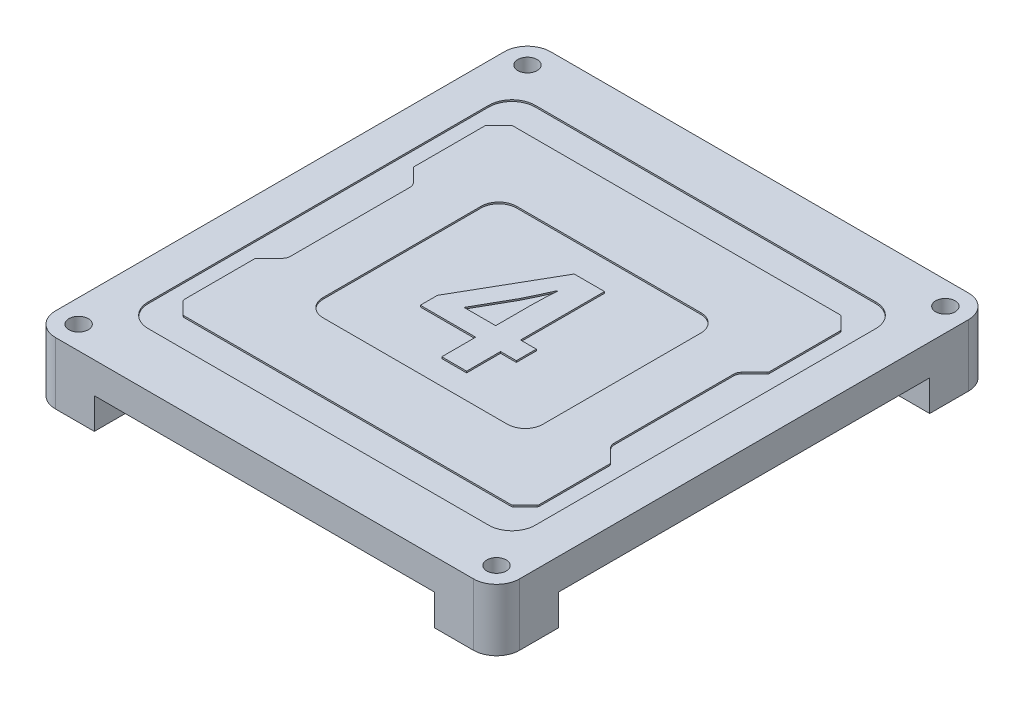
from build123d import *

# Parameters (mm, degrees)
EXTRUDE_1_DEPTH     = 4
EXTRUDE_2_DEPTH     = 4
SKETCH_3_R          = 1.25
CUT_EXTRUDE_1_DEPTH = 15
CUT_EXTRUDE_2_DEPTH = 0.2
EXTRUDE_5_DEPTH     = 0.2
EXTRUDE_6_DEPTH     = 0.2
SKETCH_13_R         = 2.280555424
SKETCH_13_R_2       = 2.93479419
SKETCH_13_R_3       = 2.630805897
SKETCH_13_R_4       = 2.84821008
EXTRUDE_7_DEPTH     = 0.2


with BuildPart() as part:
    # 草图1 → 凸台-拉伸1 (new body)
    with BuildSketch(Plane(origin=(0, 0, 0), x_dir=(1, 0, 0), z_dir=(0, 1, 0))):
        with BuildLine():
            Line((-27.00005461, -31.987363475), (27.00005461, -31.987363475))
            ThreePointArc((27.00005461, -31.987363475), (29.112398272, -31.112402082), (29.987359665, -29.00005842))
            Line((29.987359665, -29.00005842), (29.987359665, 29.00005842))
            ThreePointArc((29.987359665, 29.00005842), (29.112398272, 31.112402082), (27.00005461, 31.987363475))
            Line((27.00005461, 31.987363475), (-27.00005461, 31.987363475))
            ThreePointArc((-27.00005461, 31.987363475), (-29.112398272, 31.112402082), (-29.987359665, 29.00005842))
            Line((-29.987359665, 29.00005842), (-29.987359665, -29.00005842))
            ThreePointArc((-29.987359665, -29.00005842), (-29.112398272, -31.112402082), (-27.00005461, -31.987363475))
        make_face()
    extrude(amount=EXTRUDE_1_DEPTH)

    # 草图2 → 凸台-拉伸2 (add)
    with BuildSketch(Plane.XZ):
        with BuildLine():
            Line((-21.987359665, 23.987363475), (-21.987359665, 31.987363475))
            Line((-21.987359665, 31.987363475), (-27.00005461, 31.987363475))
            ThreePointArc((-27.00005461, 31.987363475), (-29.112398272, 31.112402082), (-29.987359665, 29.00005842))
            Line((-29.987359665, 29.00005842), (-29.987359665, 23.987363475))
            Line((-29.987359665, 23.987363475), (-21.987359665, 23.987363475))
        make_face()
        with BuildLine():
            Line((21.987359665, -23.987363475), (21.987359665, -31.987363475))
            Line((21.987359665, -31.987363475), (27.00005461, -31.987363475))
            ThreePointArc((27.00005461, -31.987363475), (29.112398272, -31.112402082), (29.987359665, -29.00005842))
            Line((29.987359665, -29.00005842), (29.987359665, -23.987363475))
            Line((29.987359665, -23.987363475), (21.987359665, -23.987363475))
        make_face()
        with BuildLine():
            Line((21.987359665, 23.987363475), (29.987359665, 23.987363475))
            Line((29.987359665, 23.987363475), (29.987359665, 29.00005842))
            ThreePointArc((29.987359665, 29.00005842), (29.112398272, 31.112402082), (27.00005461, 31.987363475))
            Line((27.00005461, 31.987363475), (21.987359665, 31.987363475))
            Line((21.987359665, 31.987363475), (21.987359665, 23.987363475))
        make_face()
        with BuildLine():
            Line((-29.987359665, -23.987363475), (-29.987359665, -29.00005842))
            ThreePointArc((-29.987359665, -29.00005842), (-29.112398272, -31.112402082), (-27.00005461, -31.987363475))
            Line((-27.00005461, -31.987363475), (-21.987359665, -31.987363475))
            Line((-21.987359665, -31.987363475), (-21.987359665, -23.987363475))
            Line((-21.987359665, -23.987363475), (-29.987359665, -23.987363475))
        make_face()
    extrude(amount=EXTRUDE_2_DEPTH)

    # 草图3 → 切除-拉伸1 (cut)
    with BuildSketch(Plane.XZ.offset(4)):
        with Locations(Location((-27.00005461, 29.00005842, 0), (0, 0, 270))):
            Circle(SKETCH_3_R)
        with Locations(Location((27.00005461, 29.00005842, 0), (0, 0, 270))):
            Circle(SKETCH_3_R)
        with Locations(Location((27.00005461, -29.00005842, 0), (0, 0, 270))):
            Circle(SKETCH_3_R)
        with Locations(Location((-27.00005461, -29.00005842, 0), (0, 0, 270))):
            Circle(SKETCH_3_R)
    extrude(amount=-CUT_EXTRUDE_1_DEPTH, mode=Mode.SUBTRACT)

    # 草图4 → 切除-拉伸2 (cut)
    with BuildSketch(Plane(origin=(0, 4, 0), x_dir=(1, 0, 0), z_dir=(0, 1, 0))):
        with BuildLine():
            Line((-22, -25), (22, -25))
            ThreePointArc((22, -25), (24.121320344, -24.121320344), (25, -22))
            Line((25, -22), (25, 22))
            ThreePointArc((25, 22), (24.121320344, 24.121320344), (22, 25))
            Line((22, 25), (-22, 25))
            ThreePointArc((-22, 25), (-24.121320344, 24.121320344), (-25, 22))
            Line((-25, 22), (-25, -22))
            ThreePointArc((-25, -22), (-24.121320344, -24.121320344), (-22, -25))
        make_face()
    extrude(amount=-CUT_EXTRUDE_2_DEPTH, mode=Mode.SUBTRACT)

    # 草图9 → 凸台-拉伸5 (add)
    with BuildSketch(Plane(origin=(0, 3.8, 0), x_dir=(1, 0, 0), z_dir=(0, 1, 0))):
        with BuildLine():
            ThreePointArc((-21.208751083, 8.458751083), (-20.987642877, 8.127839267), (-20.91, 7.737502166))
            Line((-20.91, 7.737502166), (-20.91, -7.737502166))
            ThreePointArc((-20.91, -7.737502166), (-20.987642877, -8.127839267), (-21.208751083, -8.458751083))
            Line((-21.208751083, -8.458751083), (-22.850416306, -10.100416306))
            ThreePointArc((-22.850416306, -10.100416306), (-22.924119041, -10.210720244), (-22.95, -10.340832611))
            Line((-22.95, -10.340832611), (-22.95, -19.409167389))
            ThreePointArc((-22.95, -19.409167389), (-22.924119041, -19.539279756), (-22.850416306, -19.649583694))
            Line((-22.850416306, -19.649583694), (-21.349583694, -21.150416306))
            ThreePointArc((-21.349583694, -21.150416306), (-21.239279756, -21.224119041), (-21.109167389, -21.25))
            Line((-21.109167389, -21.25), (21.109167389, -21.25))
            ThreePointArc((21.109167389, -21.25), (21.239279756, -21.224119041), (21.349583694, -21.150416306))
            Line((21.349583694, -21.150416306), (22.850416306, -19.649583694))
            ThreePointArc((22.850416306, -19.649583694), (22.924119041, -19.539279756), (22.95, -19.409167389))
            Line((22.95, -19.409167389), (22.95, -10.340832611))
            ThreePointArc((22.95, -10.340832611), (22.924119041, -10.210720244), (22.850416306, -10.100416306))
            Line((22.850416306, -10.100416306), (21.208751083, -8.458751083))
            ThreePointArc((21.208751083, -8.458751083), (20.987642877, -8.127839267), (20.91, -7.737502166))
            Line((20.91, -7.737502166), (20.91, 7.737502166))
            ThreePointArc((20.91, 7.737502166), (20.987642877, 8.127839267), (21.208751083, 8.458751083))
            Line((21.208751083, 8.458751083), (22.850416306, 10.100416306))
            ThreePointArc((22.850416306, 10.100416306), (22.924119041, 10.210720244), (22.95, 10.340832611))
            Line((22.95, 10.340832611), (22.95, 19.409167389))
            ThreePointArc((22.95, 19.409167389), (22.924119041, 19.539279756), (22.850416306, 19.649583694))
            Line((22.850416306, 19.649583694), (21.349583694, 21.150416306))
            ThreePointArc((21.349583694, 21.150416306), (21.239279756, 21.224119041), (21.109167389, 21.25))
            Line((21.109167389, 21.25), (-21.109167389, 21.25))
            ThreePointArc((-21.109167389, 21.25), (-21.239279756, 21.224119041), (-21.349583694, 21.150416306))
            Line((-21.349583694, 21.150416306), (-22.850416306, 19.649583694))
            ThreePointArc((-22.850416306, 19.649583694), (-22.924119041, 19.539279756), (-22.95, 19.409167389))
            Line((-22.95, 19.409167389), (-22.95, 10.340832611))
            ThreePointArc((-22.95, 10.340832611), (-22.924119041, 10.210720244), (-22.850416306, 10.100416306))
            Line((-22.850416306, 10.100416306), (-21.208751083, 8.458751083))
        make_face()
        with BuildLine():
            ThreePointArc((-14.688, -17.765), (-16.15, -19.227), (-17.612, -17.765))
            ThreePointArc((-17.612, -17.765), (-16.15, -16.303), (-14.688, -17.765))
        make_face(mode=Mode.SUBTRACT)
        with BuildLine():
            ThreePointArc((14.688, -17.765), (16.15, -16.303), (17.612, -17.765))
            ThreePointArc((17.612, -17.765), (16.15, -19.227), (14.688, -17.765))
        make_face(mode=Mode.SUBTRACT)
        with BuildLine():
            Line((11.9, -12.495), (-11.9, -12.495))
            ThreePointArc((-11.9, -12.495), (-13.522810063, -11.822810063), (-14.195, -10.2))
            Line((-14.195, -10.2), (-14.195, 10.2))
            ThreePointArc((-14.195, 10.2), (-13.522810063, 11.822810063), (-11.9, 12.495))
            Line((-11.9, 12.495), (11.9, 12.495))
            ThreePointArc((11.9, 12.495), (13.522810063, 11.822810063), (14.195, 10.2))
            Line((14.195, 10.2), (14.195, -10.2))
            ThreePointArc((14.195, -10.2), (13.522810063, -11.822810063), (11.9, -12.495))
        make_face(mode=Mode.SUBTRACT)
        with BuildLine():
            ThreePointArc((-14.688, 17.765), (-16.15, 16.303), (-17.612, 17.765))
            ThreePointArc((-17.612, 17.765), (-16.15, 19.227), (-14.688, 17.765))
        make_face(mode=Mode.SUBTRACT)
        with BuildLine():
            ThreePointArc((17.612, 17.765), (16.15, 16.303), (14.688, 17.765))
            ThreePointArc((14.688, 17.765), (16.15, 19.227), (17.612, 17.765))
        make_face(mode=Mode.SUBTRACT)
    extrude(amount=EXTRUDE_5_DEPTH)

    # 草图12 → 凸台-拉伸6 (add)
    with BuildSketch(Plane(origin=(0, 3.8, 0), x_dir=(1, 0, 0), z_dir=(0, 1, 0))):
        Polygon((5.362596469, -4.798672993), (5.362596469, -2.219483683), (3.321803619, -2.219483683), (3.321803619, 8.634725488), (-0.595580356, 8.634725488), (-7.046362352, -2.587805787), (-7.046362352, -4.798672993), (0.108141316, -4.798672993), (0.108141316, -9.18520475), (3.321803619, -9.18520475), (3.321803619, -4.798672993), align=None)
        with BuildLine():
            add(Edge.make_bspline(
                [(-1.346216807, 2.419233234), (-1.215389858, 2.676405088), (-0.953971645, 3.190285503), (-0.591881771, 3.983382076), (-0.22871235, 4.799127855), (0.024319607, 5.348664428), (0.153889522, 5.630065273)],
                knots=[0, 0, 0, 0, 0.976764423, 1.951769216, 2.951163759, 4, 4, 4, 4], degree=3))
            Line((0.153889522, 5.630065273), (0.248885651, 5.632179686))
            add(Edge.make_bspline(
                [(0.248885651, 5.632179686), (0.211585261, 5.077369517), (0.137462974, 3.974866313), (0.116695103, 2.87007222), (0.106378201, 2.321241135)],
                knots=[0, 0, 0, 0, 1.006455431, 2, 2, 2, 2], degree=3))
            Line((0.106378201, 2.321241135), (0.108141316, -2.219483683))
            Line((0.108141316, -2.219483683), (-3.949986994, -2.219483683))
            Line((-3.949986994, -2.219483683), (-3.949986994, -2.171163716))
            Line((-3.949986994, -2.171163716), (-1.346216807, 2.419233234))
        make_face(mode=Mode.SUBTRACT)
    extrude(amount=EXTRUDE_6_DEPTH)

    # 草图13 → 凸台-拉伸7 (add)
    with BuildSketch(Plane(origin=(0, 3.8, 0), x_dir=(1, 0, 0), z_dir=(0, 1, 0))):
        with Locations((-16.15, 17.765)):
            Circle(SKETCH_13_R)
        with Locations((16.15, 17.765)):
            Circle(SKETCH_13_R_2)
        with Locations((16.15, -17.765)):
            Circle(SKETCH_13_R_3)
        with Locations((-16.15, -17.765)):
            Circle(SKETCH_13_R_4)
    extrude(amount=EXTRUDE_7_DEPTH)


solid = part.part
